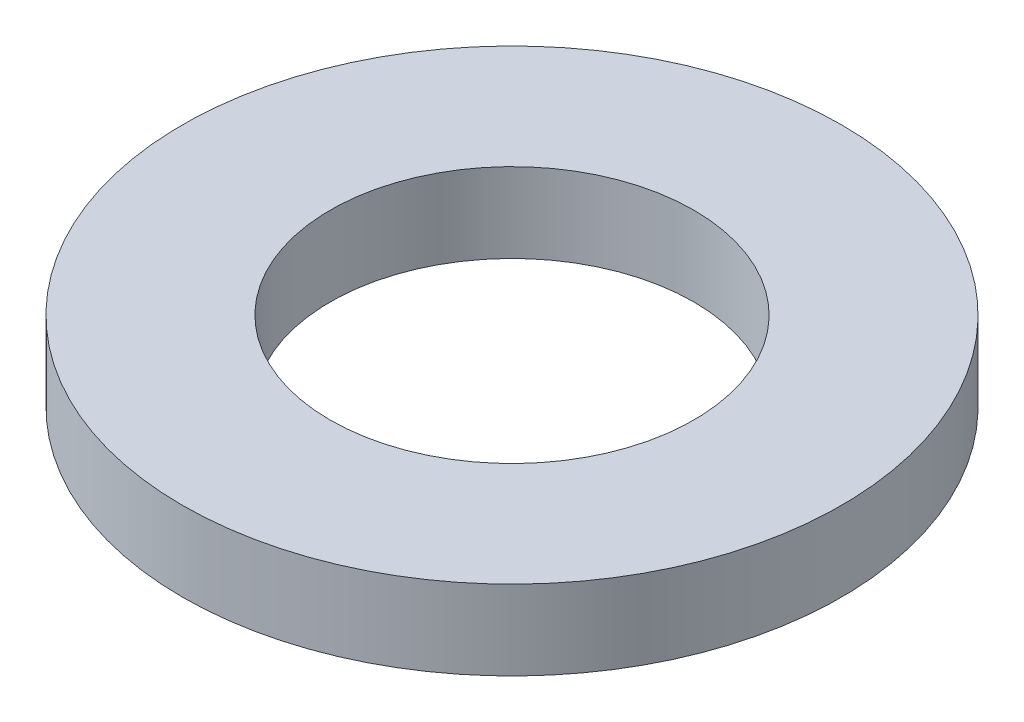
from build123d import *

# Parameters (mm, degrees)
SKETCH1_R           = 2.9
SKETCH1_R_2         = 1.6
BOSS_EXTRUDE1_DEPTH = 0.7


with BuildPart() as part:
    # Sketch1 → Boss-Extrude1 (new body)
    with BuildSketch(Plane(origin=(0, 0, 0), x_dir=(1, 0, 0), z_dir=(0, 1, 0))):
        Circle(SKETCH1_R)
        Circle(SKETCH1_R_2, mode=Mode.SUBTRACT)
    extrude(amount=BOSS_EXTRUDE1_DEPTH)


solid = part.part
